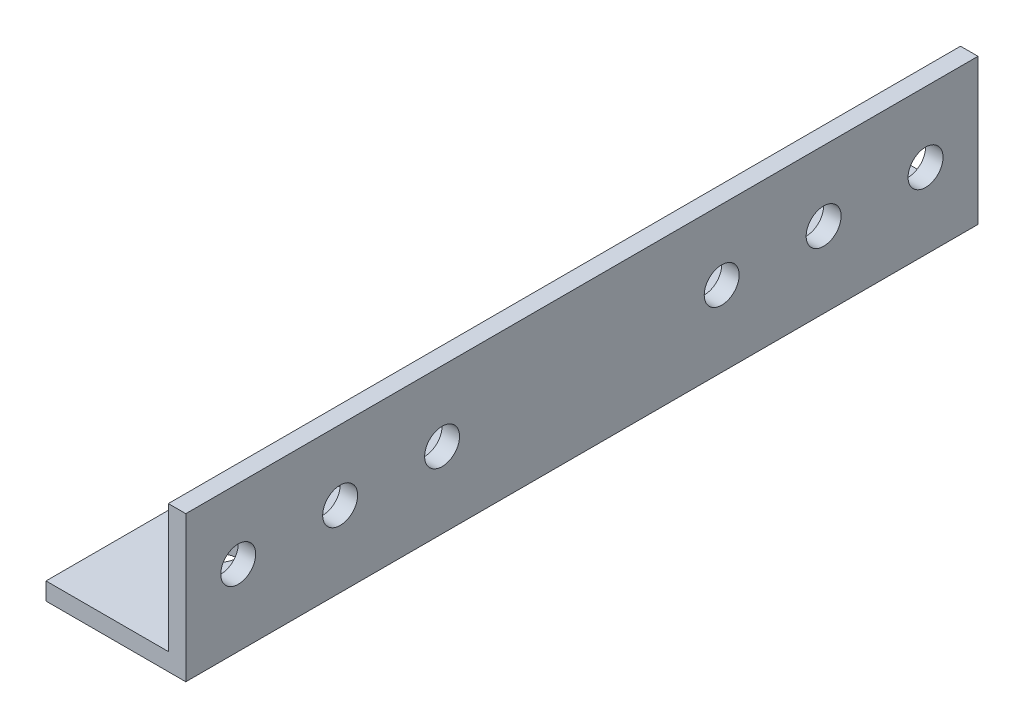
from build123d import *

# Parameters (mm, degrees)
SALIENTE_EXTRUIR1_DEPTH = 136
CROQUIS2_R              = 3
CORTAR_EXTRUIR1_DEPTH   = 25
CROQUIS3_R              = 3
CORTAR_EXTRUIR2_DEPTH   = 26


with BuildPart() as part:
    # Croquis1 → Saliente-Extruir1 (new body)
    with BuildSketch(Plane.XY):
        Polygon((0, 0), (24, 0), (24, 25), (21, 25), (21, 3), (0, 3), align=None)
    extrude(amount=SALIENTE_EXTRUIR1_DEPTH)

    # Croquis2 → Cortar-Extruir1 (cut, through all)
    with BuildSketch(Plane(origin=(24, 0, 0), x_dir=(0, 0, -1), z_dir=(1, 0, 0))):
        with Locations((-127, 13)):
            Circle(CROQUIS2_R)
        with Locations((-109.5, 13)):
            Circle(CROQUIS2_R)
        with Locations((-92, 13)):
            Circle(CROQUIS2_R)
        with Locations((-9, 13)):
            Circle(CROQUIS2_R)
        with Locations((-26.5, 13)):
            Circle(CROQUIS2_R)
        with Locations((-44, 13)):
            Circle(CROQUIS2_R)
    extrude(amount=-CORTAR_EXTRUIR1_DEPTH, mode=Mode.SUBTRACT)

    # Croquis3 → Cortar-Extruir2 (cut, through all)
    with BuildSketch(Plane.XZ):
        with Locations((10, 19.8)):
            Circle(CROQUIS3_R)
        with Locations((10, 42)):
            Circle(CROQUIS3_R)
        with Locations((10, 116.2)):
            Circle(CROQUIS3_R)
        with Locations((10, 94)):
            Circle(CROQUIS3_R)
    extrude(amount=-CORTAR_EXTRUIR2_DEPTH, mode=Mode.SUBTRACT)


solid = part.part
